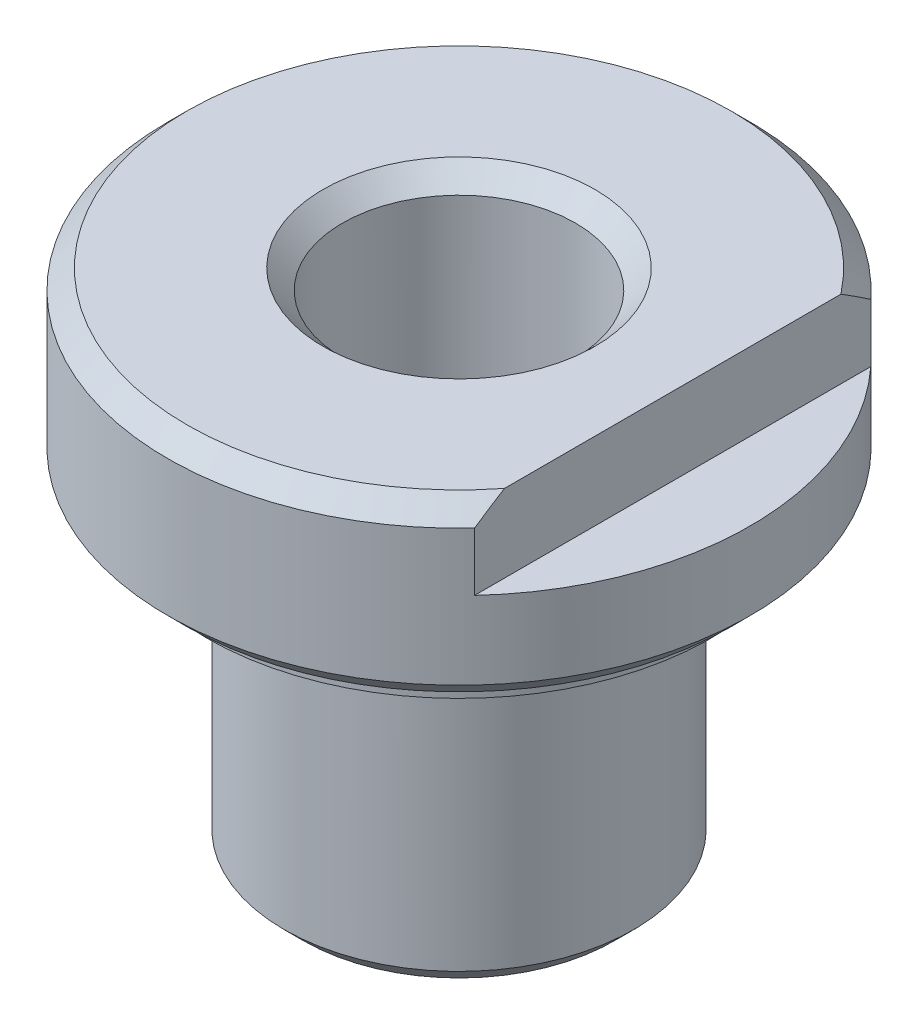
from build123d import *

# Parameters (mm, degrees)
SKETCH_2_R          = 6
CUT_EXTRUDE_1_DEPTH = 27
CUT_EXTRUDE_2_DEPTH = 4
CHAMFER_3_SIZE      = 1
CHAMFER_4_SIZE      = 0.5


with BuildPart() as part:
    # 草图1 → 旋转1 (revolve)
    with BuildSketch(Plane.XY):
        Polygon((0, 0), (9, 0), (9, 15), (8, 15), (8, 16), (8, 16.5), (10, 16.5), (10, 16), (13, 16), (13, 17), (15, 17), (15, 26), (0, 26), align=None)
    revolve(axis=Axis((0, 26, 0), (0, -1, 0)))

    # 草图2 → 切除-拉伸1 (cut, through all)
    with BuildSketch(Plane.XZ):
        Circle(SKETCH_2_R)
    extrude(amount=-CUT_EXTRUDE_1_DEPTH, mode=Mode.SUBTRACT)

    # 草图3 → 切除-拉伸2 (cut)
    with BuildSketch(Plane(origin=(0, 26, 0), x_dir=(1, 0, 0), z_dir=(0, 1, 0))):
        with BuildLine():
            Line((11, 10.198039027), (11, -10.198039027))
            ThreePointArc((11, -10.198039027), (15, 0), (11, 10.198039027))
        make_face()
    extrude(amount=-CUT_EXTRUDE_2_DEPTH, mode=Mode.SUBTRACT)

    # 倒角3
    chamfer_3_edges = [part.edges().sort_by_distance(p)[0] for p in [
        (-9, 0, 0),
        (-15, 17, 0),
        (-6, 26, 0),
        (-15, 26, 0),
    ]]
    chamfer(chamfer_3_edges, length=CHAMFER_3_SIZE)

    # 倒角4
    chamfer_4_edges = [part.edges().sort_by_distance(p)[0] for p in [
        (-9, 15, 0),
        (-6, 0, 0),
    ]]
    chamfer(chamfer_4_edges, length=CHAMFER_4_SIZE)


solid = part.part
